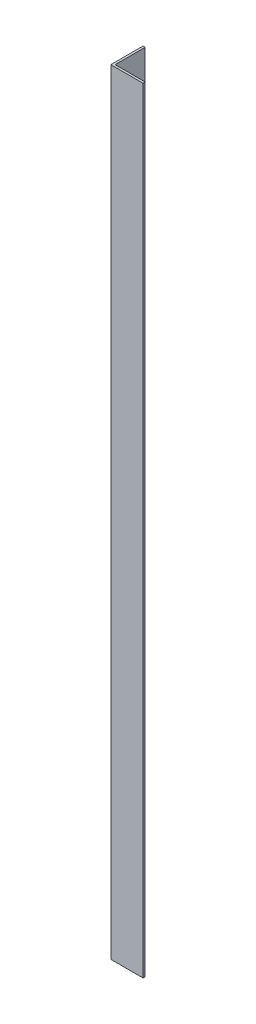
from build123d import *

# Parameters (mm, degrees)
EXTRUDE_1_DEPTH = 360


with BuildPart() as part:
    # Эскиз1 → Бобышка-Вытянуть1 (new body)
    with BuildSketch(Plane(origin=(0, 0, 0), x_dir=(1, 0, 0), z_dir=(0, 1, 0))):
        Polygon((0, 0), (0, 15), (1, 15), (1, 1), (15, 1), (15, 0), align=None)
    extrude(amount=EXTRUDE_1_DEPTH)


solid = part.part
